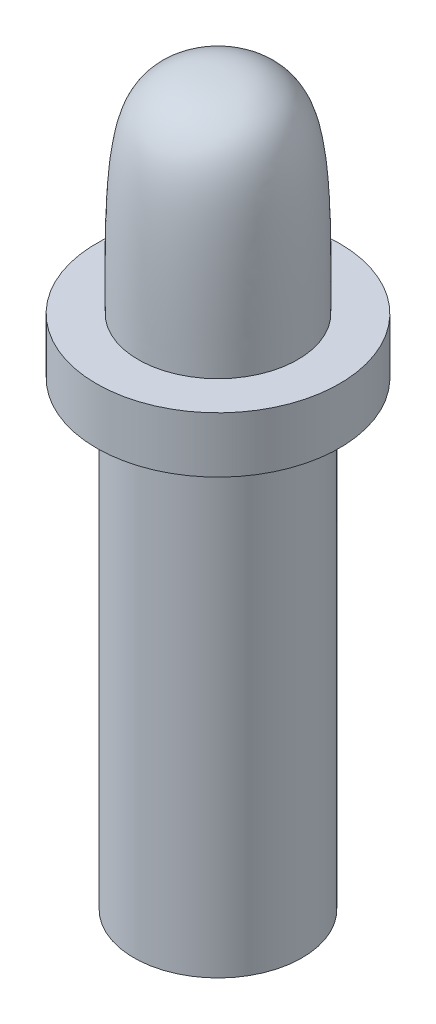
from build123d import *


with BuildPart() as part:
    # Sketch1 → Revolve2 (revolve)
    with BuildSketch(Plane.XY):
        Polygon((0, -13.46), (0, 1.629027856), (-3.555, 1.629027856), (-3.555, 0), (-2.459666551, 0), (-2.459666551, -13.46), align=None)
    revolve(axis=Axis((0, 0, 0), (0, 1, 0)))

    # Sketch1_4 → Revolve3 (revolve)
    with BuildSketch(Plane.XY):
        with BuildLine():
            Line((-2.333703088, 1.629027856), (0, 1.629027856))
            Line((0, 1.629027856), (0, 7.775203178))
            add(Edge.make_bspline(
                [(-2.333703088, 1.629027856), (-2.333703088, 2.660675753), (-2.410669001, 6.452671382), (-1.428759418, 7.527143246), (-0.659148129, 7.775203178), (0, 7.775203178)],
                knots=[0, 0, 0, 0, 0.421509284, 0.743045007, 1, 1, 1, 1], degree=3))
        make_face()
    revolve(axis=Axis((0, 0, 0), (0, 1, 0)))


solid = part.part
